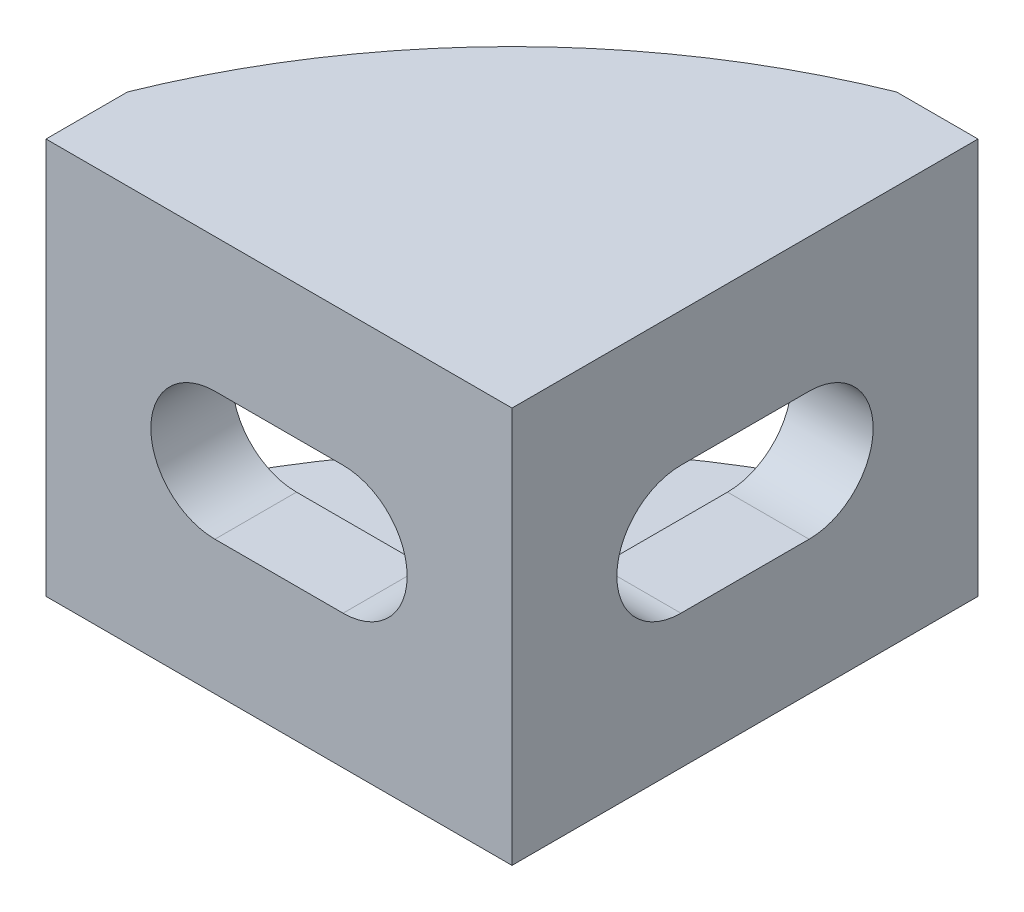
from build123d import *

# Parameters (mm, degrees)
BOSS_EXTRUDE1_DEPTH = 8.5
SKETCH2_W           = 16.5
SKETCH2_H           = 13
CUT_EXTRUDE1_DEPTH  = 16.5
CUT_EXTRUDE2_DEPTH  = 3.5
CUT_EXTRUDE3_DEPTH  = 3.5


with BuildPart() as part:
    # Sketch1 → Boss-Extrude1 (new body, symmetric)
    with BuildSketch(Plane(origin=(0, 0, 0), x_dir=(1, 0, 0), z_dir=(0, 1, 0))):
        with BuildLine():
            Line((0, 20), (0, 0))
            Line((0, 0), (-20, 0))
            Line((-20, 0), (-20, 3.5))
            ThreePointArc((-20, 3.5), (-13.435028843, 13.435028843), (-3.5, 20))
            Line((-3.5, 20), (0, 20))
        make_face()
    extrude(amount=BOSS_EXTRUDE1_DEPTH, both=True)

    # Sketch2 → Cut-Extrude1 (cut)
    with BuildSketch(Plane.ZY.offset(20)):
        with Locations((-11.75, 0)):
            Rectangle(SKETCH2_W, SKETCH2_H)
    extrude(amount=-CUT_EXTRUDE1_DEPTH, mode=Mode.SUBTRACT)

    # Sketch4 → Cut-Extrude2 (cut)
    with BuildSketch(Plane.XY):
        with BuildLine():
            Line((-7.25, 2.75), (-12.75, 2.75))
            ThreePointArc((-12.75, 2.75), (-15.5, 0), (-12.75, -2.75))
            Line((-12.75, -2.75), (-7.25, -2.75))
            ThreePointArc((-7.25, -2.75), (-4.5, 0), (-7.25, 2.75))
        make_face()
    extrude(amount=-CUT_EXTRUDE2_DEPTH, mode=Mode.SUBTRACT)

    # Sketch5 → Cut-Extrude3 (cut)
    with BuildSketch(Plane(origin=(0, 0, 0), x_dir=(0, 0, -1), z_dir=(1, 0, 0))):
        with BuildLine():
            Line((7.25, 2.75), (12.75, 2.75))
            ThreePointArc((12.75, 2.75), (15.5, 0), (12.75, -2.75))
            Line((12.75, -2.75), (7.25, -2.75))
            ThreePointArc((7.25, -2.75), (4.5, 0), (7.25, 2.75))
        make_face()
    extrude(amount=-CUT_EXTRUDE3_DEPTH, mode=Mode.SUBTRACT)


solid = part.part
